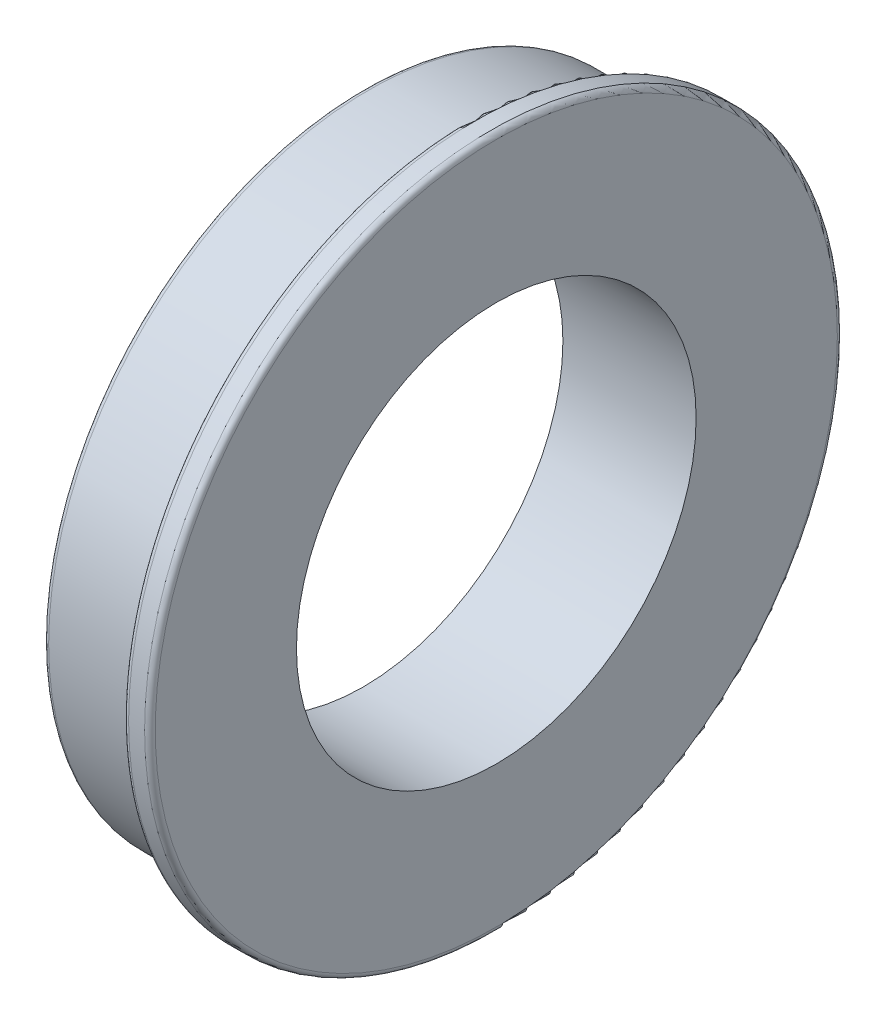
from build123d import *

# Parameters (mm, degrees)
SKETCH_1_R          = 12
EXTRUDE_1_DEPTH     = 4
SKETCH_2_R          = 13
EXTRUDE_2_DEPTH     = 1
SKETCH_3_R          = 7.5
CUT_EXTRUDE_1_DEPTH = 6
FILLET_1_R          = 0.2


with BuildPart() as part:
    # 草图1 → 凸台-拉伸1 (new body)
    with BuildSketch(Plane(origin=(0, 0, 0), x_dir=(0, 0, -1), z_dir=(1, 0, 0))):
        Circle(SKETCH_1_R)
    extrude(amount=EXTRUDE_1_DEPTH)

    # 草图2 → 凸台-拉伸2 (add)
    with BuildSketch(Plane(origin=(4, 0, 0), x_dir=(0, 0, -1), z_dir=(1, 0, 0))):
        Circle(SKETCH_2_R)
    extrude(amount=EXTRUDE_2_DEPTH)

    # 草图3 → 切除-拉伸1 (cut, through all)
    with BuildSketch(Plane.ZY):
        Circle(SKETCH_3_R)
    extrude(amount=-CUT_EXTRUDE_1_DEPTH, mode=Mode.SUBTRACT)

    # 圆角1
    fillet_1_edges = [part.edges().sort_by_distance(p)[0] for p in [
        (0, 0, 12),
        (4, 0, 13),
        (5, 0, 13),
    ]]
    fillet(fillet_1_edges, radius=FILLET_1_R)


solid = part.part
